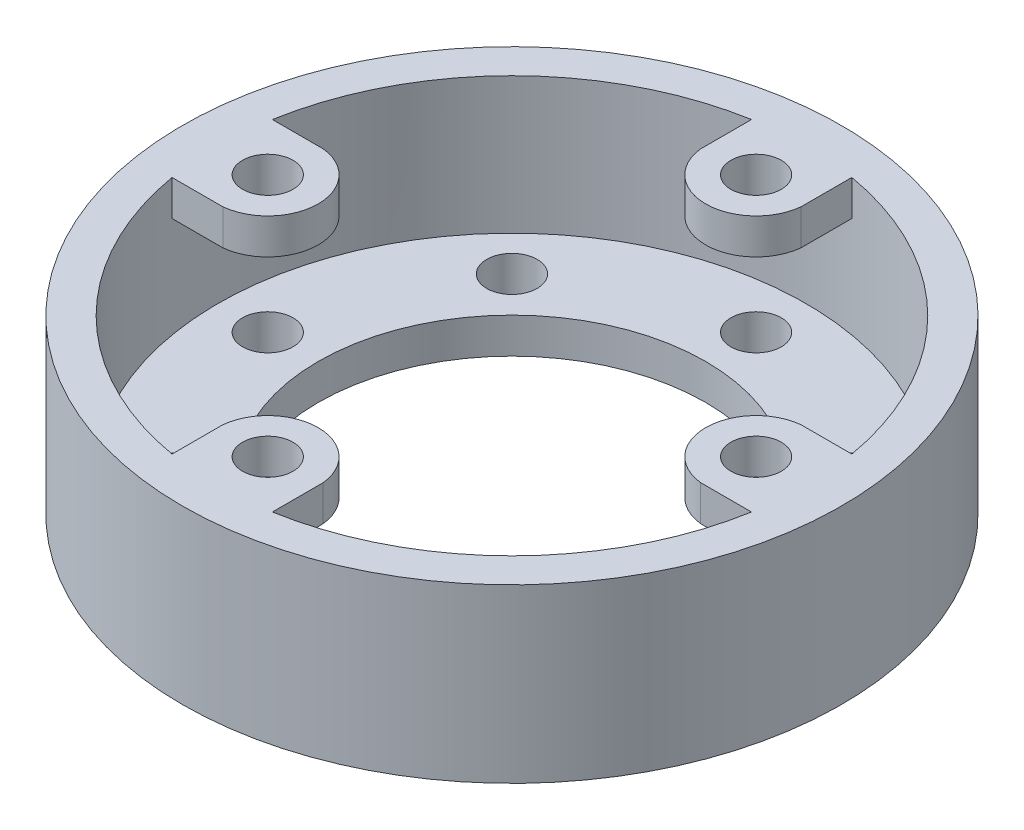
from build123d import *

# Parameters (mm, degrees)
SKETCH1_R           = 25.65
SKETCH1_R_2         = 16.9
SKETCH1_R_3         = 2.2
BOSS_EXTRUDE1_DEPTH = 3.1
SKETCH1_3_R         = 28.75
SKETCH1_3_R_2       = 25.65
BOSS_EXTRUDE2_DEPTH = 15
SKETCH2_R           = 2.2
BOSS_EXTRUDE4_DEPTH = 3.1


with BuildPart() as part:
    # Sketch1 → Boss-Extrude1 (new body)
    with BuildSketch(Plane(origin=(0, 0, 0), x_dir=(1, 0, 0), z_dir=(0, 1, 0))):
        Circle(SKETCH1_R)
        Circle(SKETCH1_R_2, mode=Mode.SUBTRACT)
        with Locations((0, 21.3)):
            Circle(SKETCH1_R_3, mode=Mode.SUBTRACT)
        with Locations((15.061374439, 15.061374439)):
            Circle(SKETCH1_R_3, mode=Mode.SUBTRACT)
        with Locations((21.3, 0)):
            Circle(SKETCH1_R_3, mode=Mode.SUBTRACT)
        with Locations((15.061374439, -15.061374439)):
            Circle(SKETCH1_R_3, mode=Mode.SUBTRACT)
        with Locations((0, -21.3)):
            Circle(SKETCH1_R_3, mode=Mode.SUBTRACT)
        with Locations((-15.061374439, -15.061374439)):
            Circle(SKETCH1_R_3, mode=Mode.SUBTRACT)
        with Locations((-21.3, 0)):
            Circle(SKETCH1_R_3, mode=Mode.SUBTRACT)
        with Locations((-15.061374439, 15.061374439)):
            Circle(SKETCH1_R_3, mode=Mode.SUBTRACT)
    extrude(amount=BOSS_EXTRUDE1_DEPTH)

    # Sketch1_3 → Boss-Extrude2 (add)
    with BuildSketch(Plane(origin=(0, 0, 0), x_dir=(1, 0, 0), z_dir=(0, 1, 0))):
        Circle(SKETCH1_3_R)
        Circle(SKETCH1_3_R_2, mode=Mode.SUBTRACT)
    extrude(amount=BOSS_EXTRUDE2_DEPTH)

    # Sketch2 → Boss-Extrude4 (add)
    # profile 1 of 4: a face of its own
    with BuildSketch(Plane(origin=(0, 11.9, 0), x_dir=(1, 0, 0), z_dir=(0, 1, 0))):
        with BuildLine():
            ThreePointArc((-20.845539906, -4.376467299), (-16.9, 0), (-20.845539906, 4.376467299))
            Line((-20.845539906, 4.376467299), (-25.273880469, 4.376467299))
            ThreePointArc((-25.273880469, 4.376467299), (-25.65, 0), (-25.273880469, -4.376467299))
            Line((-25.273880469, -4.376467299), (-20.845539906, -4.376467299))
        make_face()
        with Locations((-21.3, 0)):
            Circle(SKETCH2_R, mode=Mode.SUBTRACT)
    # profile 2 of 4: a face of its own
    with BuildSketch(Plane(origin=(0, 11.9, 0), x_dir=(1, 0, 0), z_dir=(0, 1, 0))):
        with BuildLine():
            ThreePointArc((4.376467299, 25.273880469), (0, 25.65), (-4.376467299, 25.273880469))
            Line((-4.376467299, 25.273880469), (-4.376467299, 20.845539906))
            ThreePointArc((-4.376467299, 20.845539906), (0, 16.9), (4.376467299, 20.845539906))
            Line((4.376467299, 20.845539906), (4.376467299, 25.273880469))
        make_face()
        with Locations((0, 21.3)):
            Circle(SKETCH2_R, mode=Mode.SUBTRACT)
    # profile 3 of 4: a face of its own
    with BuildSketch(Plane(origin=(0, 11.9, 0), x_dir=(1, 0, 0), z_dir=(0, 1, 0))):
        with BuildLine():
            Line((-4.376467299, -20.845539906), (-4.376467299, -25.273880469))
            ThreePointArc((-4.376467299, -25.273880469), (0, -25.65), (4.376467299, -25.273880469))
            Line((4.376467299, -25.273880469), (4.376467299, -20.845539906))
            ThreePointArc((4.376467299, -20.845539906), (0, -16.9), (-4.376467299, -20.845539906))
        make_face()
        with Locations((0, -21.3)):
            Circle(SKETCH2_R, mode=Mode.SUBTRACT)
    # profile 4 of 4: a face of its own
    with BuildSketch(Plane(origin=(0, 11.9, 0), x_dir=(1, 0, 0), z_dir=(0, 1, 0))):
        with BuildLine():
            ThreePointArc((25.273880469, -4.376467299), (25.65, 0), (25.273880469, 4.376467299))
            Line((25.273880469, 4.376467299), (20.845539906, 4.376467299))
            ThreePointArc((20.845539906, 4.376467299), (16.9, 0), (20.845539906, -4.376467299))
            Line((20.845539906, -4.376467299), (25.273880469, -4.376467299))
        make_face()
        with Locations((21.3, 0)):
            Circle(SKETCH2_R, mode=Mode.SUBTRACT)
    extrude(amount=BOSS_EXTRUDE4_DEPTH)


solid = part.part
